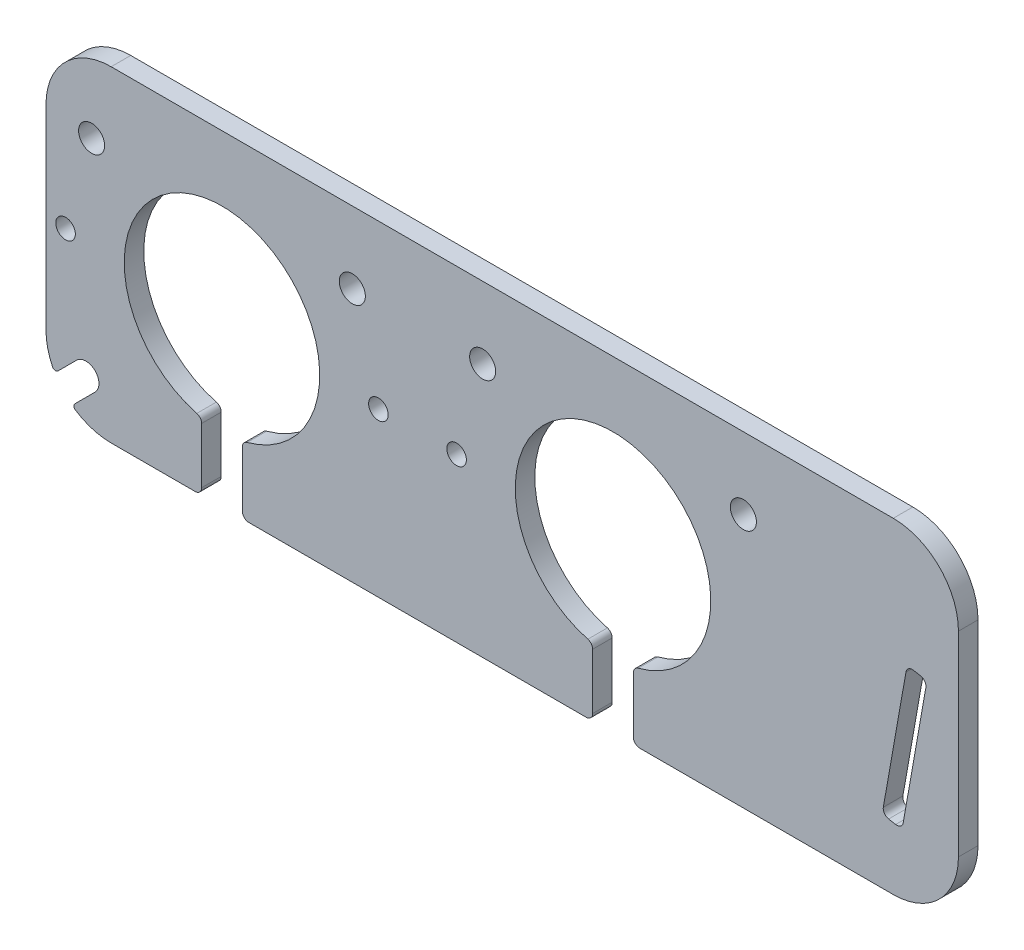
from build123d import *

# Parameters (mm, degrees)
ESQUISSE1_R        = 1.5
ESQUISSE1_R_2      = 2
BOSS_EXTRU_1_DEPTH = 3


with BuildPart() as part:
    # Esquisse1 → Boss.-Extru.1 (new body)
    with BuildSketch(Plane.XY):
        with BuildLine():
            Line((-47, 50), (73, 50))
            ThreePointArc((73, 50), (80.071067812, 47.071067812), (83, 40))
            Line((83, 40), (83, 10))
            ThreePointArc((83, 10), (80.071067812, 2.928932188), (73, 0))
            Line((73, 0), (47, 0))
            Line((47, 0), (34.119561541, 0))
            ThreePointArc((34.119561541, 0), (33.41245476, 0.292893219), (33.119561541, 1))
            Line((33.119561541, 1), (33.119561541, 9.539430389))
            ThreePointArc((33.119561541, 9.539430389), (33.326632605, 10.148744513), (33.862088945, 10.505715989))
            ThreePointArc((33.862088945, 10.505715989), (30, 40), (26.137911055, 10.505715989))
            ThreePointArc((26.137911055, 10.505715989), (26.673367395, 10.148744513), (26.880438459, 9.539430389))
            Line((26.880438459, 9.539430389), (26.880438459, 1))
            ThreePointArc((26.880438459, 1), (26.58754524, 0.292893219), (25.880438459, 0))
            Line((25.880438459, 0), (-25.880438459, 0))
            ThreePointArc((-25.880438459, 0), (-26.58754524, 0.292893219), (-26.880438459, 1))
            Line((-26.880438459, 1), (-26.880438459, 9.539430389))
            ThreePointArc((-26.880438459, 9.539430389), (-26.673367395, 10.148744513), (-26.137911055, 10.505715989))
            ThreePointArc((-26.137911055, 10.505715989), (-30, 40), (-33.862088945, 10.505715989))
            ThreePointArc((-33.862088945, 10.505715989), (-33.326632605, 10.148744513), (-33.119561541, 9.539430389))
            Line((-33.119561541, 9.539430389), (-33.119561541, 1))
            ThreePointArc((-33.119561541, 1), (-33.41245476, 0.292893219), (-34.119561541, 0))
            Line((-34.119561541, 0), (-47, 0))
            ThreePointArc((-47, 0), (-49.871560265, 0.42116178), (-52.501242243, 1.649171671))
            ThreePointArc((-52.501242243, 1.649171671), (-52.723609687, 2.016078741), (-52.579733522, 2.420266478))
            Line((-52.579733522, 2.420266478), (-49.464466094, 5.535533906))
            ThreePointArc((-49.464466094, 5.535533906), (-49.464466094, 8.363961031), (-52.292893219, 8.363961031))
            Line((-52.292893219, 8.363961031), (-55.181690934, 5.475163315))
            ThreePointArc((-55.181690934, 5.475163315), (-55.617572947, 5.335541283), (-55.98446771, 5.60917548))
            ThreePointArc((-55.98446771, 5.60917548), (-56.742809582, 7.746633308), (-57, 10))
            Line((-57, 10), (-57, 40))
            ThreePointArc((-57, 40), (-54.071067812, 47.071067812), (-47, 50))
        make_face()
        with Locations((-6, 25)):
            Circle(ESQUISSE1_R, mode=Mode.SUBTRACT)
        with Locations((-54, 25)):
            Circle(ESQUISSE1_R, mode=Mode.SUBTRACT)
        with Locations((6, 25)):
            Circle(ESQUISSE1_R, mode=Mode.SUBTRACT)
        with Locations((50, 39)):
            Circle(ESQUISSE1_R_2, mode=Mode.SUBTRACT)
        with Locations((10, 39)):
            Circle(ESQUISSE1_R_2, mode=Mode.SUBTRACT)
        with Locations((-10, 39)):
            Circle(ESQUISSE1_R_2, mode=Mode.SUBTRACT)
        with Locations((-50, 39)):
            Circle(ESQUISSE1_R_2, mode=Mode.SUBTRACT)
        with BuildLine():
            Line((76.105551896, 31.349468926), (77.188840425, 31.158455931))
            ThreePointArc((77.188840425, 31.158455931), (77.834344291, 30.747224614), (78, 30))
            Line((78, 30), (74.527036447, 10.30384494))
            ThreePointArc((74.527036447, 10.30384494), (74.11580513, 9.658341073), (73.368580516, 9.492685364))
            Line((73.368580516, 9.492685364), (72.285291988, 9.68369836))
            ThreePointArc((72.285291988, 9.68369836), (71.639788121, 10.094929677), (71.474132412, 10.842154291))
            Line((71.474132412, 10.842154291), (74.947095966, 30.538309351))
            ThreePointArc((74.947095966, 30.538309351), (75.358327282, 31.183813217), (76.105551896, 31.349468926))
        make_face(mode=Mode.SUBTRACT)
    extrude(amount=BOSS_EXTRU_1_DEPTH)


solid = part.part
